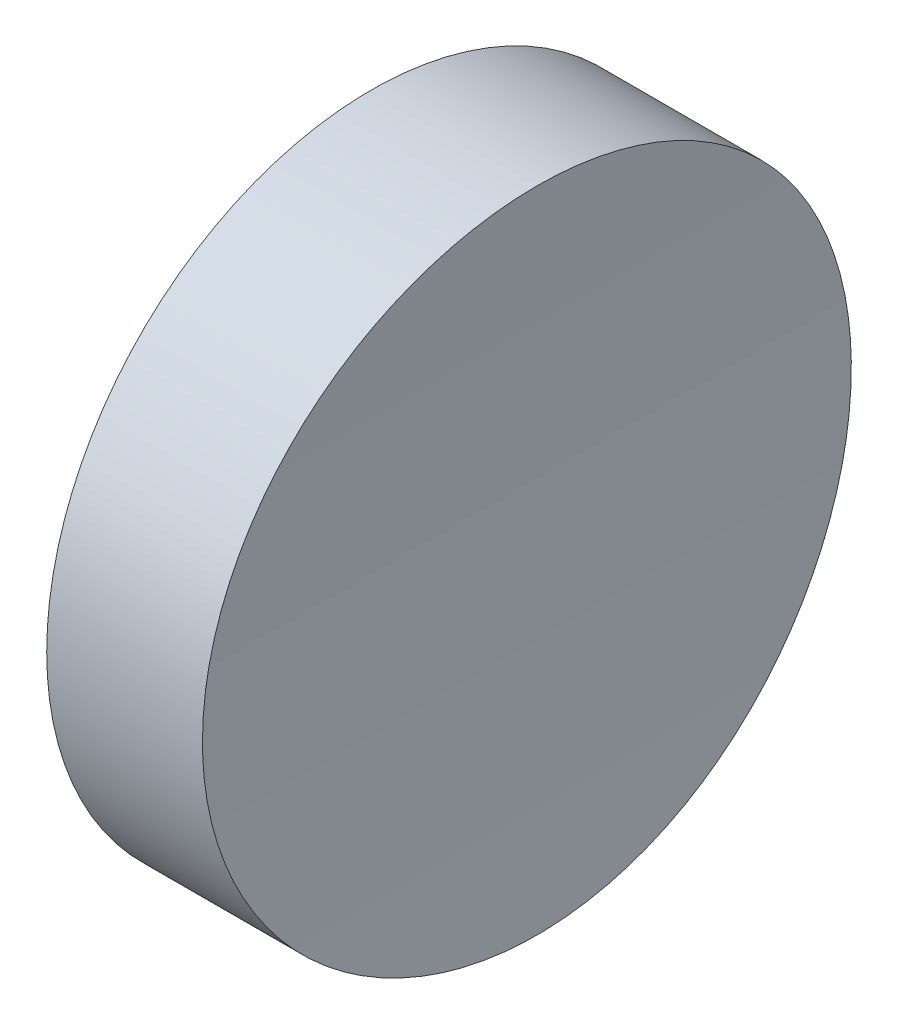
from build123d import *

# Parameters (mm, degrees)
SKETCH_1_R               = 12.5
EXTRUDE_1_DEPTH          = 10
SKETCH_2_R               = 200
CUT_EXTRUDE_1_DEPTH      = 13.5
CUT_EXTRUDE_1_DEPTH_BACK = 13.5


with BuildPart() as part:
    # 草图1 → 凸台-拉伸1 (new body)
    with BuildSketch(Plane(origin=(0, 0, 0), x_dir=(0, 0, -1), z_dir=(1, 0, 0))):
        Circle(SKETCH_1_R)
    extrude(amount=EXTRUDE_1_DEPTH)

    # 草图2 → 切除-拉伸1 (cut, two sides)
    with BuildSketch(Plane.XY) as cut_extrude_1_sk:
        with Locations((206, 0)):
            Circle(SKETCH_2_R)
    extrude(amount=CUT_EXTRUDE_1_DEPTH, mode=Mode.SUBTRACT)
    extrude(cut_extrude_1_sk.sketch, amount=-CUT_EXTRUDE_1_DEPTH_BACK, mode=Mode.SUBTRACT)


solid = part.part
